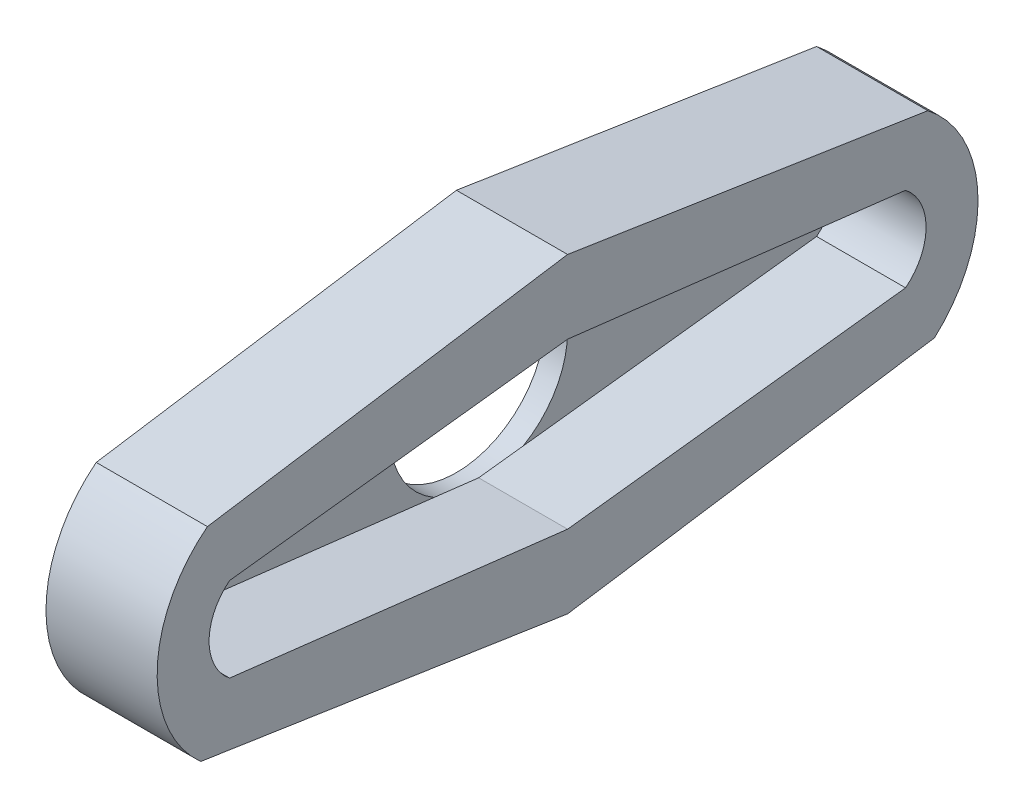
from build123d import *

# Parameters (mm, degrees)
BOSS_EXTRUDE1_DEPTH = 4
SKETCH2_R           = 4
BOSS_EXTRUDE2_DEPTH = 1


with BuildPart() as part:
    # Sketch1 → Boss-Extrude1 (new body)
    with BuildSketch(Plane(origin=(0, 0, 0), x_dir=(0, 0, -1), z_dir=(1, 0, 0))):
        with BuildLine():
            Line((0, 7), (-16.2, 4.5))
            ThreePointArc((-16.2, 4.5), (-18.456321812, 0.070210727), (-16.5, -4.5))
            Line((-16.5, -4.5), (0, -7))
            Line((0, -7), (16.5, -4.5))
            ThreePointArc((16.5, -4.5), (18.456321812, 0.070210727), (16.2, 4.5))
            Line((16.2, 4.5), (0, 7))
        make_face()
        with BuildLine():
            Line((0, 3.7), (-15.2, 1.9))
            ThreePointArc((-15.2, 1.9), (-16.123290742, 0), (-15.2, -1.9))
            Line((-15.2, -1.9), (0, -3.7))
            Line((0, -3.7), (15.2, -1.9))
            ThreePointArc((15.2, -1.9), (16.123290742, 0), (15.2, 1.9))
            Line((15.2, 1.9), (0, 3.7))
        make_face(mode=Mode.SUBTRACT)
    extrude(amount=BOSS_EXTRUDE1_DEPTH)

    # Sketch2 → Boss-Extrude2 (add)
    with BuildSketch(Plane(origin=(0, 0, 0), x_dir=(0, 0, -1), z_dir=(1, 0, 0))):
        with BuildLine():
            Line((0, 7), (-16.2, 4.5))
            ThreePointArc((-16.2, 4.5), (-18.456321812, 0.070210727), (-16.5, -4.5))
            Line((-16.5, -4.5), (0, -7))
            Line((0, -7), (16.5, -4.5))
            ThreePointArc((16.5, -4.5), (18.456321812, 0.070210727), (16.2, 4.5))
            Line((16.2, 4.5), (0, 7))
        make_face()
        Circle(SKETCH2_R, mode=Mode.SUBTRACT)
    extrude(amount=-BOSS_EXTRUDE2_DEPTH)


solid = part.part
